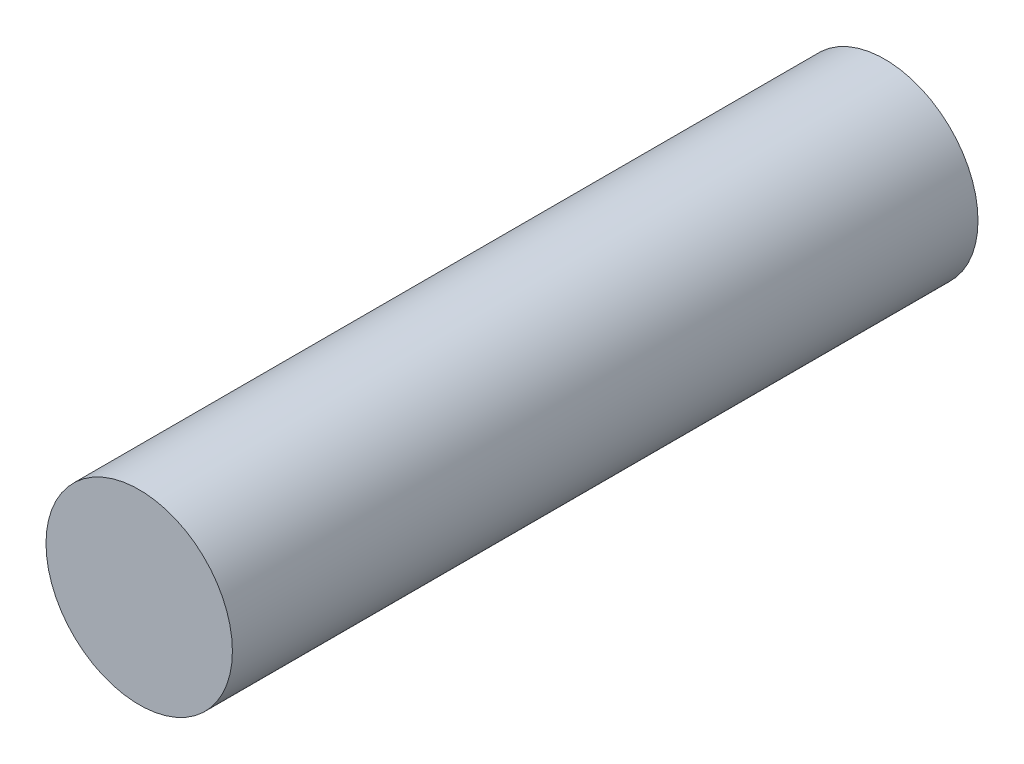
from build123d import *

# Parameters (mm, degrees)
SKETCH1_R           = 5
BOSS_EXTRUDE1_DEPTH = 40


with BuildPart() as part:
    # Sketch1 → Boss-Extrude1 (new body)
    with BuildSketch(Plane.XY):
        Circle(SKETCH1_R)
    extrude(amount=BOSS_EXTRUDE1_DEPTH)


solid = part.part
